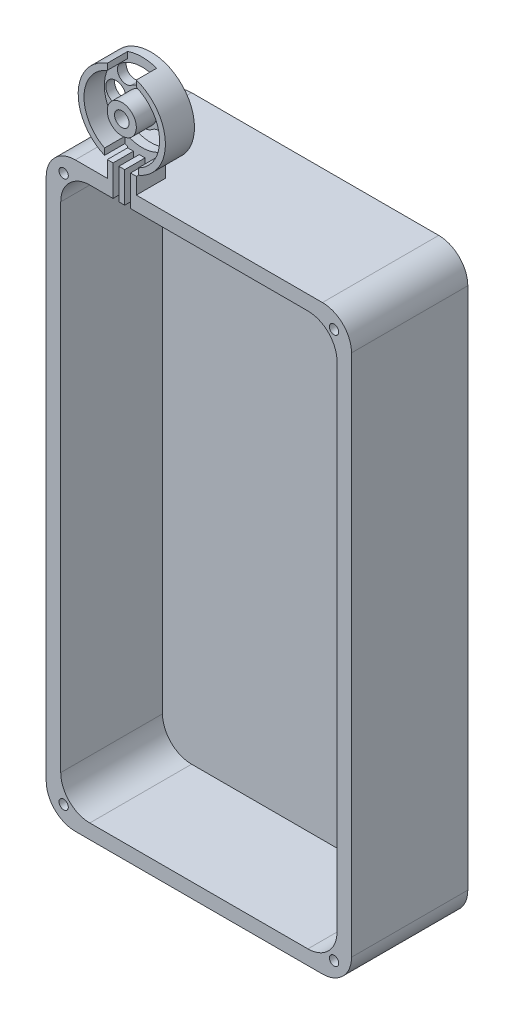
from build123d import *

# Parameters (mm, degrees)
SKETCH1_W           = 105
SKETCH1_H           = 200
BOSS_EXTRUDE1_DEPTH = 40
SKETCH2_W           = 95
SKETCH2_H           = 190
CUT_EXTRUDE1_DEPTH  = 35
FILLET1_R           = 10
SKETCH3_R           = 1.6
CUT_EXTRUDE2_DEPTH  = 35
BOSS_EXTRUDE2_DEPTH = 10
SKETCH6_R           = 2.5
CUT_EXTRUDE3_DEPTH  = 10
SKETCH7_R           = 13
SKETCH7_R_2         = 5
CUT_EXTRUDE5_DEPTH  = 7
SKETCH9_W           = 10
SKETCH9_H           = 4.718519443
CUT_EXTRUDE8_DEPTH  = 7
SKETCH10_W          = 11.630652226
SKETCH10_H          = 3.85031924
CUT_EXTRUDE11_DEPTH = 7
SKETCH11_W          = 2
SKETCH11_H          = 11.091513068
SKETCH11_H_2        = 11.156323384
CUT_EXTRUDE12_DEPTH = 7
CUT_EXTRUDE13_DEPTH = 7
SKETCH13_R          = 3.5
CUT_EXTRUDE14_DEPTH = 7


with BuildPart() as part:
    # Sketch1 → Boss-Extrude1 (new body)
    with BuildSketch(Plane.XY):
        with Locations((52.5, 100)):
            Rectangle(SKETCH1_W, SKETCH1_H)
    extrude(amount=BOSS_EXTRUDE1_DEPTH)

    # Sketch2 → Cut-Extrude1 (cut)
    with BuildSketch(Plane.XY.offset(40)):
        with Locations((52.5, 100)):
            Rectangle(SKETCH2_W, SKETCH2_H)
    extrude(amount=-CUT_EXTRUDE1_DEPTH, mode=Mode.SUBTRACT)

    # Fillet1
    fillet1_edges = [part.edges().sort_by_distance(p)[0] for p in [
        (5, 195, 22.5),
        (100, 195, 22.5),
        (100, 5, 22.5),
        (5, 5, 22.5),
        (0, 200, 20),
        (105, 200, 20),
        (105, 0, 20),
        (0, 0, 20),
    ]]
    fillet(fillet1_edges, radius=FILLET1_R)

    # Sketch3 → Cut-Extrude2 (cut)
    with BuildSketch(Plane.XY.offset(40)):
        with Locations((6, 194)):
            Circle(SKETCH3_R)
        with Locations((99, 194)):
            Circle(SKETCH3_R)
        with Locations((99, 6)):
            Circle(SKETCH3_R)
        with Locations((6, 6)):
            Circle(SKETCH3_R)
    extrude(amount=-CUT_EXTRUDE2_DEPTH, mode=Mode.SUBTRACT)

    # Sketch4 → Boss-Extrude2 (add)
    with BuildSketch(Plane.XY.offset(40)):
        with BuildLine():
            Line((21, 200), (21, 206))
            ThreePointArc((21, 206), (26, 235.142135624), (31, 206))
            Line((31, 206), (31, 200))
            Line((31, 200), (21, 200))
        make_face()
    extrude(amount=-BOSS_EXTRUDE2_DEPTH)

    # Sketch6 → Cut-Extrude3 (cut)
    with BuildSketch(Plane.XY.offset(40)):
        with Locations((26, 220.142135624)):
            Circle(SKETCH6_R)
    extrude(amount=-CUT_EXTRUDE3_DEPTH, mode=Mode.SUBTRACT)

    # Sketch7 → Cut-Extrude5 (cut)
    with BuildSketch(Plane.XY.offset(40)):
        with Locations((26, 220.142135624)):
            Circle(SKETCH7_R)
        with Locations((26, 220.142135624)):
            Circle(SKETCH7_R_2, mode=Mode.SUBTRACT)
    extrude(amount=-CUT_EXTRUDE5_DEPTH, mode=Mode.SUBTRACT)

    # Sketch9 → Cut-Extrude8 (cut)
    with BuildSketch(Plane.XY.offset(40)):
        with Locations((26, 233.858468974)):
            Rectangle(SKETCH9_W, SKETCH9_H)
    extrude(amount=-CUT_EXTRUDE8_DEPTH, mode=Mode.SUBTRACT)

    # Sketch10 → Cut-Extrude11 (cut)
    with BuildSketch(Plane.XY.offset(40)):
        with Locations((25.887552525, 207.506070883)):
            Rectangle(SKETCH10_W, SKETCH10_H)
    extrude(amount=-CUT_EXTRUDE11_DEPTH, mode=Mode.SUBTRACT)

    # Sketch11 → Cut-Extrude12 (cut)
    with BuildSketch(Plane.XY.offset(40)):
        with Locations((24, 200.229066802)):
            Rectangle(SKETCH11_W, SKETCH11_H)
        with Locations((28, 200.296138355)):
            Rectangle(SKETCH11_W, SKETCH11_H_2)
    extrude(amount=-CUT_EXTRUDE12_DEPTH, mode=Mode.SUBTRACT)

    # Sketch12 → Cut-Extrude13 (cut)
    with BuildSketch(Plane(origin=(0, 0, 30), x_dir=(-1, 0, 0), z_dir=(0, 0, -1))):
        with BuildLine():
            ThreePointArc((-18.666666667, 229.640673523), (-26, 232.142135624), (-33.333333333, 229.640673523))
            ThreePointArc((-33.333333333, 229.640673523), (-33.874634475, 225.432705715), (-29.666666667, 224.891404573))
            ThreePointArc((-29.666666667, 224.891404573), (-26, 226.142135624), (-22.333333333, 224.891404573))
            ThreePointArc((-22.333333333, 224.891404573), (-18.125365525, 225.432705715), (-18.666666667, 229.640673523))
        make_face()
        with BuildLine():
            ThreePointArc((-18.666666667, 210.643597725), (-26, 208.142135624), (-33.333333333, 210.643597725))
            ThreePointArc((-33.333333333, 210.643597725), (-33.874634475, 214.851565533), (-29.666666667, 215.392866674))
            ThreePointArc((-29.666666667, 215.392866674), (-26, 214.142135624), (-22.333333333, 215.392866674))
            ThreePointArc((-22.333333333, 215.392866674), (-18.125365525, 214.851565533), (-18.666666667, 210.643597725))
        make_face()
    extrude(amount=-CUT_EXTRUDE13_DEPTH, mode=Mode.SUBTRACT)

    # Sketch13 → Cut-Extrude14 (cut)
    with BuildSketch(Plane(origin=(0, 0, 30), x_dir=(-1, 0, 0), z_dir=(0, 0, -1))):
        with Locations((-17, 220.142135624)):
            Circle(SKETCH13_R)
        with Locations((-35, 220.142135624)):
            Circle(SKETCH13_R)
    extrude(amount=-CUT_EXTRUDE14_DEPTH, mode=Mode.SUBTRACT)


solid = part.part
